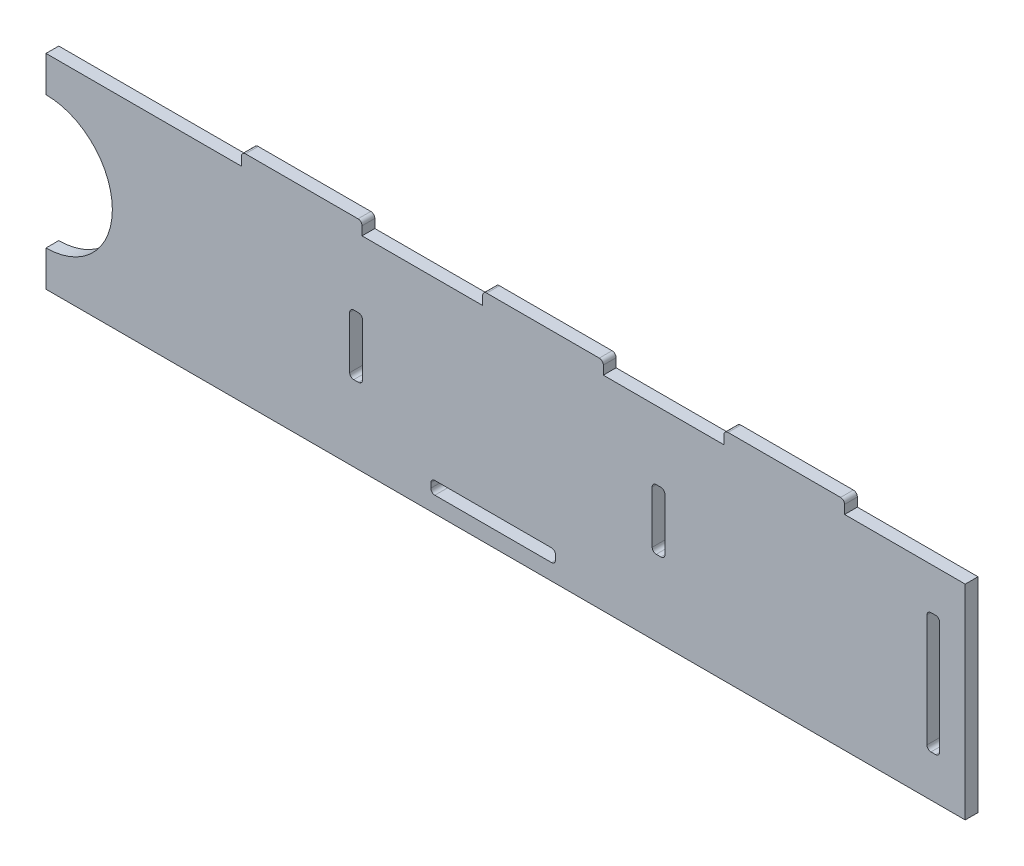
from build123d import *

# Parameters (mm, degrees)
SKETCH1_W           = 228.6
SKETCH1_H           = 50.8
BOSS_EXTRUDE1_DEPTH = 3.175
SKETCH2_W           = 30
SKETCH2_H           = 3.175
BOSS_EXTRUDE2_DEPTH = 3.175
SKETCH3_R           = 16.5
CUT_EXTRUDE1_DEPTH  = 4.175
SKETCH4_W           = 3.175
SKETCH4_H           = 30
SKETCH4_H_2         = 15
CUT_EXTRUDE2_DEPTH  = 10
SKETCH5_W           = 31
SKETCH5_H           = 3.175
CUT_EXTRUDE3_DEPTH  = 10
FILLET1_R           = 1


with BuildPart() as part:
    # Sketch1 → Boss-Extrude1 (new body)
    with BuildSketch(Plane.XY):
        Rectangle(SKETCH1_W, SKETCH1_H)
    extrude(amount=BOSS_EXTRUDE1_DEPTH)

    # Sketch2 → Boss-Extrude2 (add)
    with BuildSketch(Plane(origin=(0, 25.4, 0), x_dir=(1, 0, 0), z_dir=(0, 1, 0))):
        with Locations((69.3, -1.5875)):
            Rectangle(SKETCH2_W, SKETCH2_H)
        with Locations((9.3, -1.5875)):
            Rectangle(SKETCH2_W, SKETCH2_H)
        with Locations((-50.7, -1.5875)):
            Rectangle(SKETCH2_W, SKETCH2_H)
    extrude(amount=BOSS_EXTRUDE2_DEPTH)

    # Sketch3 → Cut-Extrude1 (cut, through all)
    with BuildSketch(Plane.XY.offset(3.175)):
        with Locations((-114.3, 0)):
            Circle(SKETCH3_R)
    extrude(amount=-CUT_EXTRUDE1_DEPTH, mode=Mode.SUBTRACT)

    # Sketch4 → Cut-Extrude2 (cut)
    with BuildSketch(Plane.XY.offset(3.175)):
        with Locations((106.3625, 0)):
            Rectangle(SKETCH4_W, SKETCH4_H)
        with Locations((38.0375, 0.9)):
            Rectangle(SKETCH4_W, SKETCH4_H_2)
        with Locations((-37.1875, 0.9)):
            Rectangle(SKETCH4_W, SKETCH4_H_2)
    extrude(amount=-CUT_EXTRUDE2_DEPTH, mode=Mode.SUBTRACT)

    # Sketch5 → Cut-Extrude3 (cut)
    with BuildSketch(Plane.XY.offset(3.175)):
        with Locations((-3.1, -19.8125)):
            Rectangle(SKETCH5_W, SKETCH5_H)
    extrude(amount=-CUT_EXTRUDE3_DEPTH, mode=Mode.SUBTRACT)

    # Fillet1
    fillet1_edges = [part.edges().sort_by_distance(p)[0] for p in [
        (-38.775, -6.6, 1.5875),
        (-38.775, 8.4, 1.5875),
        (-35.6, 8.4, 1.5875),
        (-35.6, -6.6, 1.5875),
        (104.775, -15, 1.5875),
        (104.775, 15, 1.5875),
        (107.95, 15, 1.5875),
        (107.95, -15, 1.5875),
        (39.625, 8.4, 1.5875),
        (39.625, -6.6, 1.5875),
        (36.45, -6.6, 1.5875),
        (36.45, 8.4, 1.5875),
        (12.4, -18.225, 1.5875),
        (12.4, -21.4, 1.5875),
        (-18.6, -21.4, 1.5875),
        (-18.6, -18.225, 1.5875),
        (84.3, 28.575, 1.5875),
        (54.3, 28.575, 1.5875),
        (-5.7, 28.575, 1.5875),
        (24.3, 28.575, 1.5875),
        (-65.7, 28.575, 1.5875),
        (-35.7, 28.575, 1.5875),
    ]]
    fillet(fillet1_edges, radius=FILLET1_R)


solid = part.part
